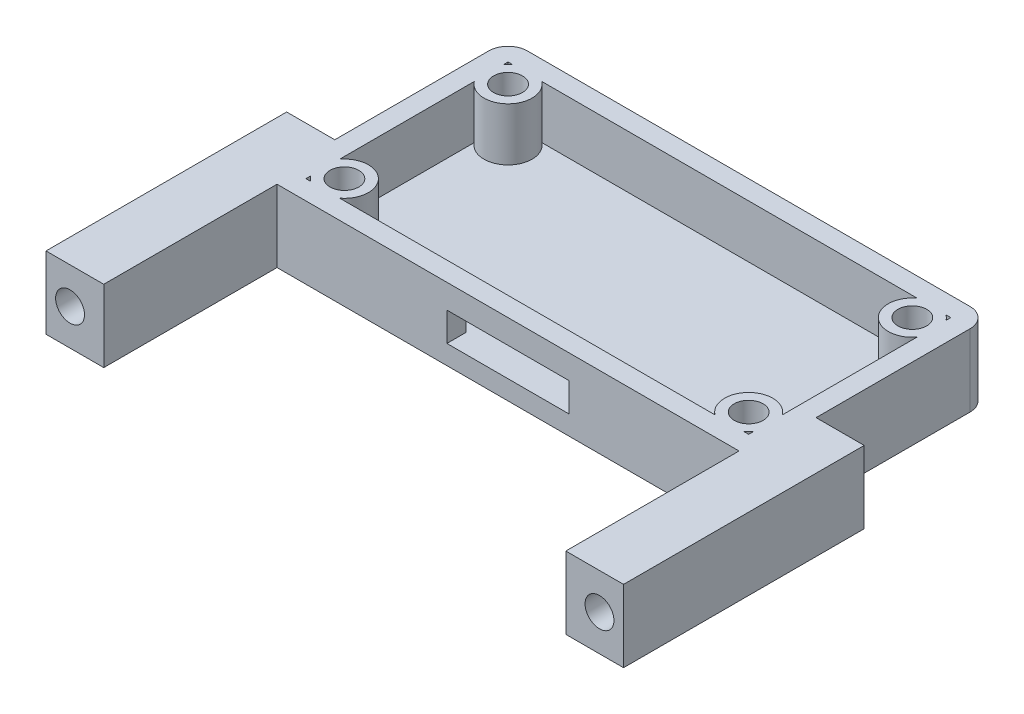
from build123d import *

# Parameters (mm, degrees)
EXTRUDE_1_DEPTH     = 2
SKETCH_2_W          = 46
SKETCH_2_H          = 21
EXTRUDE_2_DEPTH     = 5.5
SKETCH_3_R          = 2.5
SKETCH_3_R_2        = 1.5
EXTRUDE_3_DEPTH     = 5.5
CUT_EXTRUDE_2_REACH = 27
SKETCH_5_W          = 12.7
SKETCH_5_H          = 3
EXTRUDE_4_DEPTH     = 7.5
SKETCH_7_R          = 1.5
CUT_EXTRUDE_3_DEPTH = 3
EXTRUDE_5_DEPTH     = 18
EXTRUDE_6_DEPTH     = 18
SKETCH_10_W         = 5
SKETCH_10_H         = 7.5
SKETCH_10_R         = 1.5
EXTRUDE_7_DEPTH     = 5


with BuildPart() as part:
    # 草图1 → 凸台-拉伸1 (new body)
    with BuildSketch(Plane(origin=(0, 0, 0), x_dir=(1, 0, 0), z_dir=(0, 1, 0))):
        with BuildLine():
            Line((-23, 12.5), (23, 12.5))
            ThreePointArc((23, 12.5), (24.414213562, 11.914213562), (25, 10.5))
            Line((25, 10.5), (25, -10.5))
            ThreePointArc((25, -10.5), (24.414213562, -11.914213562), (23, -12.5))
            Line((23, -12.5), (-23, -12.5))
            ThreePointArc((-23, -12.5), (-24.414213562, -11.914213562), (-25, -10.5))
            Line((-25, -10.5), (-25, 10.5))
            ThreePointArc((-25, 10.5), (-24.414213562, 11.914213562), (-23, 12.5))
        make_face()
    extrude(amount=EXTRUDE_1_DEPTH)

    # 草图2 → 凸台-拉伸2 (add)
    with BuildSketch(Plane(origin=(0, 2, 0), x_dir=(1, 0, 0), z_dir=(0, 1, 0))):
        with BuildLine():
            Line((-25, 10.5), (-25, -10.5))
            ThreePointArc((-25, -10.5), (-24.414213562, -11.914213562), (-23, -12.5))
            Line((-23, -12.5), (23, -12.5))
            ThreePointArc((23, -12.5), (24.414213562, -11.914213562), (25, -10.5))
            Line((25, -10.5), (25, 10.5))
            ThreePointArc((25, 10.5), (24.414213562, 11.914213562), (23, 12.5))
            Line((23, 12.5), (-23, 12.5))
            ThreePointArc((-23, 12.5), (-24.414213562, 11.914213562), (-25, 10.5))
        make_face()
        Rectangle(SKETCH_2_W, SKETCH_2_H, mode=Mode.SUBTRACT)
    extrude(amount=EXTRUDE_2_DEPTH)

    # 草图3 → 凸台-拉伸3 (add)
    with BuildSketch(Plane(origin=(0, 2, 0), x_dir=(1, 0, 0), z_dir=(0, 1, 0))):
        with Locations((-21, 8.5)):
            Circle(SKETCH_3_R)
        with Locations((-21, 8.5)):
            Circle(SKETCH_3_R_2, mode=Mode.SUBTRACT)
        with Locations((21, 8.5)):
            Circle(SKETCH_3_R)
        with Locations((21, 8.5)):
            Circle(SKETCH_3_R_2, mode=Mode.SUBTRACT)
        with Locations((21, -8.5)):
            Circle(SKETCH_3_R)
        with Locations((21, -8.5)):
            Circle(SKETCH_3_R_2, mode=Mode.SUBTRACT)
        with Locations((-21, -8.5)):
            Circle(SKETCH_3_R)
        with Locations((-21, -8.5)):
            Circle(SKETCH_3_R_2, mode=Mode.SUBTRACT)
    extrude(amount=EXTRUDE_3_DEPTH)

    # 草图5 → 切除-拉伸2 (cut, up to next)
    with BuildSketch(Plane.XY.offset(12.5), mode=Mode.PRIVATE) as cut_extrude_2_sk1:
        with Locations((0, 3.5)):
            Rectangle(SKETCH_5_W, SKETCH_5_H)
    cut_extrude_2_tool1 = extrude(cut_extrude_2_sk1.sketch, amount=-CUT_EXTRUDE_2_REACH, mode=Mode.PRIVATE) & part.part
    add(cut_extrude_2_tool1.solids().sort_by_distance((0, 3.5, 12.5))[0], mode=Mode.SUBTRACT)

    # 草图6 → 凸台-拉伸4 (add)
    with BuildSketch(Plane.XZ):
        Polygon((23, 12.5), (30, 12.5), (30, 10.5), (25, 10.5), align=None)
        Polygon((-23, 12.5), (-30, 12.5), (-30, 10.5), (-25, 10.5), align=None)
    extrude(amount=-EXTRUDE_4_DEPTH)

    # 草图7 → 切除-拉伸3 (cut, through all)
    with BuildSketch(Plane(origin=(0, 0, 10.5), x_dir=(-1, 0, 0), z_dir=(0, 0, -1))):
        with Locations((-27.5, 3.75)):
            Circle(SKETCH_7_R)
        with Locations((27.5, 3.75)):
            Circle(SKETCH_7_R)
    extrude(amount=-CUT_EXTRUDE_3_DEPTH, mode=Mode.SUBTRACT)

    # 草图8 → 凸台-拉伸5 (add)
    with BuildSketch(Plane.XY.offset(12.5)):
        with BuildLine():
            Line((-29, 7.5), (-29, 3.75))
            ThreePointArc((-29, 3.75), (-27.5, 2.25), (-26, 3.75))
            Line((-26, 3.75), (-26, 7.5))
            Line((-26, 7.5), (-24, 7.5))
            Line((-24, 7.5), (-24, 0))
            Line((-24, 0), (-30, 0))
            Line((-30, 0), (-30, 7.5))
            Line((-30, 7.5), (-29, 7.5))
        make_face()
        with BuildLine():
            Line((29, 7.5), (29, 3.75))
            ThreePointArc((29, 3.75), (27.5, 2.25), (26, 3.75))
            Line((26, 3.75), (26, 7.5))
            Line((26, 7.5), (24, 7.5))
            Line((24, 7.5), (24, 0))
            Line((24, 0), (30, 0))
            Line((30, 0), (30, 7.5))
            Line((30, 7.5), (29, 7.5))
        make_face()
    extrude(amount=EXTRUDE_5_DEPTH)

    # 草图9 → 凸台-拉伸6 (add)
    with BuildSketch(Plane.XY.offset(12.5)):
        with BuildLine():
            Line((29, 3.75), (29, 7.5))
            Line((29, 7.5), (26, 7.5))
            Line((26, 7.5), (26, 3.75))
            ThreePointArc((26, 3.75), (27.5, 5.25), (29, 3.75))
        make_face()
        with BuildLine():
            Line((-29, 7.5), (-29, 3.75))
            ThreePointArc((-29, 3.75), (-27.5, 5.25), (-26, 3.75))
            Line((-26, 3.75), (-26, 7.5))
            Line((-26, 7.5), (-29, 7.5))
        make_face()
    extrude(amount=EXTRUDE_6_DEPTH)

    # 草图10 → 凸台-拉伸7 (add)
    with BuildSketch(Plane(origin=(0, 0, 10.5), x_dir=(-1, 0, 0), z_dir=(0, 0, -1))):
        with Locations((-27.5, 3.75)):
            Rectangle(SKETCH_10_W, SKETCH_10_H)
        with Locations((-27.5, 3.75)):
            Circle(SKETCH_10_R, mode=Mode.SUBTRACT)
        with Locations((27.5, 3.75)):
            Rectangle(SKETCH_10_W, SKETCH_10_H)
        with Locations((27.5, 3.75)):
            Circle(SKETCH_10_R, mode=Mode.SUBTRACT)
    extrude(amount=EXTRUDE_7_DEPTH)


solid = part.part
